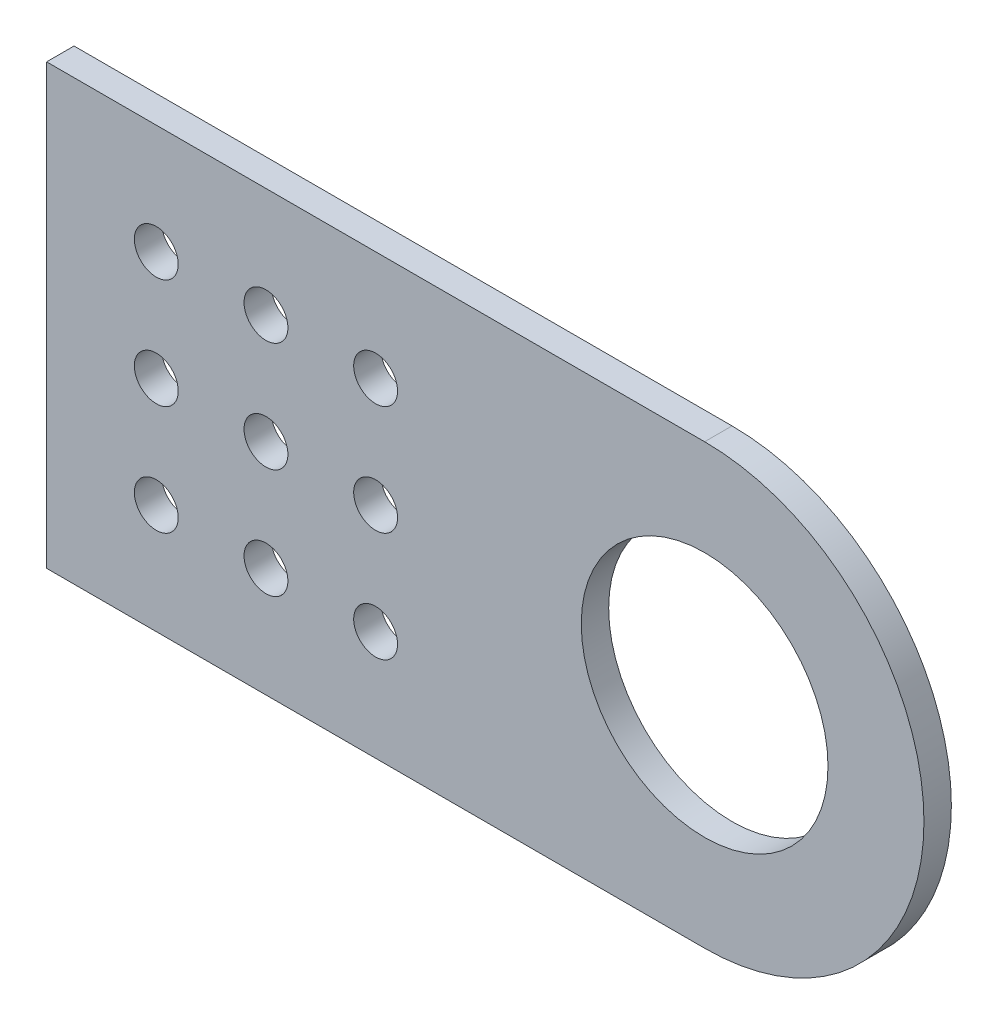
from build123d import *

# Parameters (mm, degrees)
SKETCH1_R           = 2.54
SKETCH1_R_2         = 14.2875
BOSS_EXTRUDE1_DEPTH = 3.175


with BuildPart() as part:
    # Sketch1 → Boss-Extrude1 (new body)
    with BuildSketch(Plane.XY):
        with BuildLine():
            Line((0, 0), (0, 50.8))
            Line((0, 50.8), (76.2, 50.8))
            ThreePointArc((76.2, 50.8), (101.6, 25.4), (76.2, 0))
            Line((76.2, 0), (0, 0))
        make_face()
        with Locations((12.7, 38.1)):
            Circle(SKETCH1_R, mode=Mode.SUBTRACT)
        with Locations((25.4, 38.1)):
            Circle(SKETCH1_R, mode=Mode.SUBTRACT)
        with Locations((38.1, 38.1)):
            Circle(SKETCH1_R, mode=Mode.SUBTRACT)
        with Locations((25.4, 25.4)):
            Circle(SKETCH1_R, mode=Mode.SUBTRACT)
        with Locations((38.1, 25.4)):
            Circle(SKETCH1_R, mode=Mode.SUBTRACT)
        with Locations((25.4, 12.7)):
            Circle(SKETCH1_R, mode=Mode.SUBTRACT)
        with Locations((38.1, 12.7)):
            Circle(SKETCH1_R, mode=Mode.SUBTRACT)
        with Locations((12.7, 25.4)):
            Circle(SKETCH1_R, mode=Mode.SUBTRACT)
        with Locations((12.7, 12.7)):
            Circle(SKETCH1_R, mode=Mode.SUBTRACT)
        with Locations((76.2, 25.4)):
            Circle(SKETCH1_R_2, mode=Mode.SUBTRACT)
    extrude(amount=BOSS_EXTRUDE1_DEPTH)


solid = part.part
